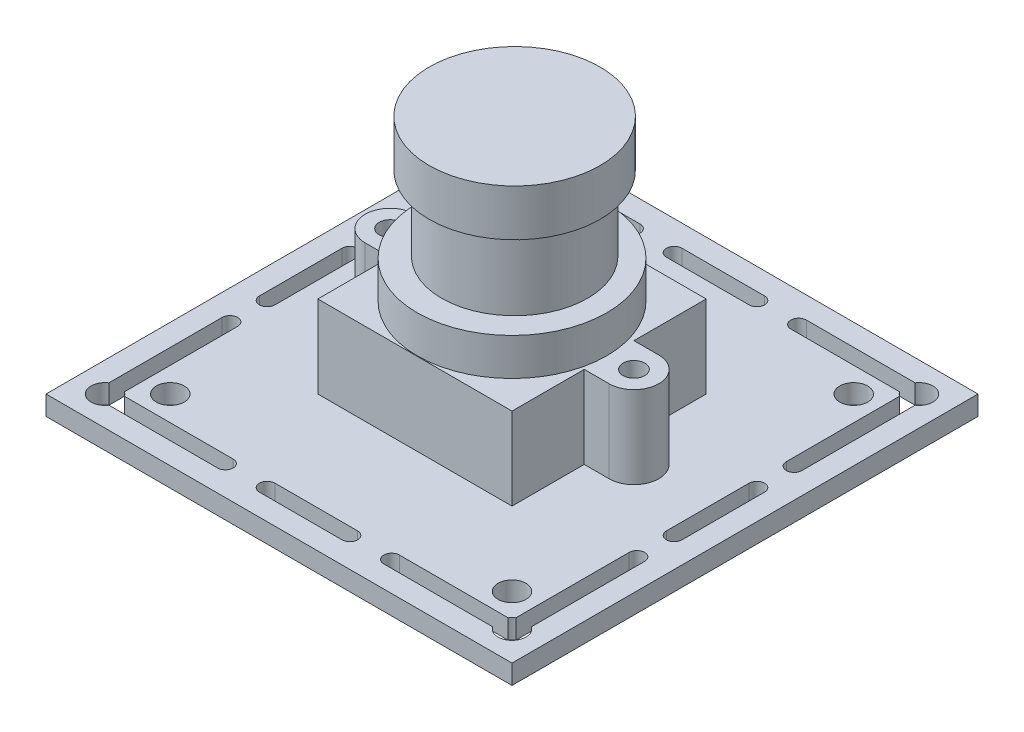
from build123d import *

# Parameters (mm, degrees)
SKETCH1_W           = 38.1
SKETCH1_H           = 38.1
BOSS_EXTRUDE1_DEPTH = 1.5875
SKETCH4_R           = 1.143
CUT_EXTRUDE2_DEPTH  = 7.874
SKETCH6_W           = 15.875
SKETCH6_H           = 15.875
BOSS_EXTRUDE2_DEPTH = 6.731
SKETCH7_R           = 0.889
BOSS_EXTRUDE3_DEPTH = 6.731
SKETCH8_R           = 7.747
BOSS_EXTRUDE4_DEPTH = 3.048
SKETCH9_R           = 5.969
BOSS_EXTRUDE5_DEPTH = 6.096
SKETCH10_R          = 6.985
BOSS_EXTRUDE6_DEPTH = 3.81
SKETCH11_W          = 9.906
SKETCH11_H          = 4.572
BOSS_EXTRUDE7_DEPTH = 8.255


with BuildPart() as part:
    # Sketch1 → Boss-Extrude1 (new body)
    with BuildSketch(Plane(origin=(0, 0, 0), x_dir=(1, 0, 0), z_dir=(0, 1, 0))):
        with Locations((-252.591789549, -315.673153846)):
            Rectangle(SKETCH1_W, SKETCH1_H)
    extrude(amount=BOSS_EXTRUDE1_DEPTH)

    # Sketch4 → Cut-Extrude2 (cut)
    with BuildSketch(Plane(origin=(0, 1.5875, 0), x_dir=(1, 0, 0), z_dir=(0, 1, 0))):
        with Locations((-266.561789549, -301.703153846)):
            Circle(SKETCH4_R)
        with Locations((-238.621789549, -301.703153846)):
            Circle(SKETCH4_R)
        with Locations((-266.561789549, -329.643153846)):
            Circle(SKETCH4_R)
        with Locations((-238.621789549, -329.643153846)):
            Circle(SKETCH4_R)
        with BuildLine():
            Line((-269.863789549, -312.294953846), (-269.863789549, -319.051353846))
            ThreePointArc((-269.863789549, -319.051353846), (-269.228789549, -319.686353846), (-268.593789549, -319.051353846))
            Line((-268.593789549, -319.051353846), (-268.593789549, -312.294953846))
            ThreePointArc((-268.593789549, -312.294953846), (-269.228789549, -311.659953846), (-269.863789549, -312.294953846))
        make_face()
        with BuildLine():
            Line((-259.385291519, -298.401153846), (-268.278408573, -298.401153846))
            ThreePointArc((-268.278408573, -298.401153846), (-270.0370126, -298.227930795), (-269.863789549, -299.986534822))
            Line((-269.863789549, -299.986534822), (-269.863789549, -309.246953846))
            ThreePointArc((-269.863789549, -309.246953846), (-269.228789549, -309.881953846), (-268.593789549, -309.246953846))
            Line((-268.593789549, -309.246953846), (-268.593789549, -299.986534822))
            ThreePointArc((-268.593789549, -299.986534822), (-268.420566498, -299.844376897), (-268.278408573, -299.671153846))
            Line((-268.278408573, -299.671153846), (-259.385291519, -299.671153846))
            ThreePointArc((-259.385291519, -299.671153846), (-258.750291519, -299.036153846), (-259.385291519, -298.401153846))
        make_face()
        with BuildLine():
            Line((-255.969989549, -298.401153846), (-249.213589549, -298.401153846))
            ThreePointArc((-249.213589549, -298.401153846), (-248.578589549, -299.036153846), (-249.213589549, -299.671153846))
            Line((-249.213589549, -299.671153846), (-255.969989549, -299.671153846))
            ThreePointArc((-255.969989549, -299.671153846), (-256.604989549, -299.036153846), (-255.969989549, -298.401153846))
        make_face()
        with BuildLine():
            Line((-236.589789549, -309.246953846), (-236.589789549, -299.986534822))
            ThreePointArc((-236.589789549, -299.986534822), (-236.7630126, -299.844376897), (-236.905170525, -299.671153846))
            Line((-236.905170525, -299.671153846), (-245.798287579, -299.671153846))
            ThreePointArc((-245.798287579, -299.671153846), (-246.433287579, -299.036153846), (-245.798287579, -298.401153846))
            Line((-245.798287579, -298.401153846), (-236.905170525, -298.401153846))
            ThreePointArc((-236.905170525, -298.401153846), (-235.146566498, -298.227930795), (-235.319789549, -299.986534822))
            Line((-235.319789549, -299.986534822), (-235.319789549, -309.246953846))
            ThreePointArc((-235.319789549, -309.246953846), (-235.954789549, -309.881953846), (-236.589789549, -309.246953846))
        make_face()
        with BuildLine():
            Line((-236.589789549, -312.294953846), (-236.589789549, -319.051353846))
            ThreePointArc((-236.589789549, -319.051353846), (-235.954789549, -319.686353846), (-235.319789549, -319.051353846))
            Line((-235.319789549, -319.051353846), (-235.319789549, -312.294953846))
            ThreePointArc((-235.319789549, -312.294953846), (-235.954789549, -311.659953846), (-236.589789549, -312.294953846))
        make_face()
        with BuildLine():
            Line((-245.798287579, -332.945153846), (-236.905170525, -332.945153846))
            ThreePointArc((-236.905170525, -332.945153846), (-235.146566498, -333.118376897), (-235.319789549, -331.35977287))
            Line((-235.319789549, -331.35977287), (-235.319789549, -322.099353846))
            ThreePointArc((-235.319789549, -322.099353846), (-235.954789549, -321.464353846), (-236.589789549, -322.099353846))
            Line((-236.589789549, -322.099353846), (-236.589789549, -331.35977287))
            ThreePointArc((-236.589789549, -331.35977287), (-236.7630126, -331.501930795), (-236.905170525, -331.675153846))
            Line((-236.905170525, -331.675153846), (-245.798287579, -331.675153846))
            ThreePointArc((-245.798287579, -331.675153846), (-246.433287579, -332.310153846), (-245.798287579, -332.945153846))
        make_face()
        with BuildLine():
            Line((-268.593789549, -322.099353846), (-268.593789549, -331.35977287))
            ThreePointArc((-268.593789549, -331.35977287), (-268.420566498, -331.501930795), (-268.278408573, -331.675153846))
            Line((-268.278408573, -331.675153846), (-259.385291519, -331.675153846))
            ThreePointArc((-259.385291519, -331.675153846), (-258.750291519, -332.310153846), (-259.385291519, -332.945153846))
            Line((-259.385291519, -332.945153846), (-268.278408573, -332.945153846))
            ThreePointArc((-268.278408573, -332.945153846), (-270.0370126, -333.118376897), (-269.863789549, -331.35977287))
            Line((-269.863789549, -331.35977287), (-269.863789549, -322.099353846))
            ThreePointArc((-269.863789549, -322.099353846), (-269.228789549, -321.464353846), (-268.593789549, -322.099353846))
        make_face()
        with BuildLine():
            Line((-255.969989549, -331.675153846), (-249.213589549, -331.675153846))
            ThreePointArc((-249.213589549, -331.675153846), (-248.578589549, -332.310153846), (-249.213589549, -332.945153846))
            Line((-249.213589549, -332.945153846), (-255.969989549, -332.945153846))
            ThreePointArc((-255.969989549, -332.945153846), (-256.604989549, -332.310153846), (-255.969989549, -331.675153846))
        make_face()
    extrude(amount=-CUT_EXTRUDE2_DEPTH, mode=Mode.SUBTRACT)

    # Sketch6 → Boss-Extrude2 (add)
    with BuildSketch(Plane(origin=(0, 1.5875, 0), x_dir=(1, 0, 0), z_dir=(0, 1, 0))):
        with Locations((-252.591789549, -315.673153846)):
            Rectangle(SKETCH6_W, SKETCH6_H)
    extrude(amount=BOSS_EXTRUDE2_DEPTH)

    # Sketch7 → Boss-Extrude3 (add)
    with BuildSketch(Plane(origin=(0, 1.5875, 0), x_dir=(1, 0, 0), z_dir=(0, 1, 0))):
        with BuildLine():
            Line((-242.622289549, -313.641153846), (-244.654289549, -313.641153846))
            Line((-244.654289549, -313.641153846), (-244.654289549, -317.705153846))
            Line((-244.654289549, -317.705153846), (-242.622289549, -317.705153846))
            ThreePointArc((-242.622289549, -317.705153846), (-240.590289549, -315.673153846), (-242.622289549, -313.641153846))
        make_face()
        with Locations((-242.622289549, -315.673153846)):
            Circle(SKETCH7_R, mode=Mode.SUBTRACT)
        with BuildLine():
            Line((-262.561289549, -317.705153846), (-260.529289549, -317.705153846))
            Line((-260.529289549, -317.705153846), (-260.529289549, -313.641153846))
            Line((-260.529289549, -313.641153846), (-262.561289549, -313.641153846))
            ThreePointArc((-262.561289549, -313.641153846), (-264.593289549, -315.673153846), (-262.561289549, -317.705153846))
        make_face()
        with Locations((-262.561289549, -315.673153846)):
            Circle(SKETCH7_R, mode=Mode.SUBTRACT)
    extrude(amount=BOSS_EXTRUDE3_DEPTH)

    # Sketch8 → Boss-Extrude4 (add)
    with BuildSketch(Plane(origin=(0, 8.3185, 0), x_dir=(1, 0, 0), z_dir=(0, 1, 0))):
        with Locations((-252.436354268, -315.828589127)):
            Circle(SKETCH8_R)
    extrude(amount=BOSS_EXTRUDE4_DEPTH)

    # Sketch9 → Boss-Extrude5 (add)
    with BuildSketch(Plane(origin=(0, 11.3665, 0), x_dir=(1, 0, 0), z_dir=(0, 1, 0))):
        with Locations((-252.465375739, -315.583143422)):
            Circle(SKETCH9_R)
    extrude(amount=BOSS_EXTRUDE5_DEPTH)

    # Sketch10 → Boss-Extrude6 (add)
    with BuildSketch(Plane(origin=(0, 17.4625, 0), x_dir=(1, 0, 0), z_dir=(0, 1, 0))):
        with Locations((-252.465375739, -315.583143422)):
            Circle(SKETCH10_R)
    extrude(amount=BOSS_EXTRUDE6_DEPTH)

    # Sketch11 → Boss-Extrude7 (add)
    with BuildSketch(Plane.XZ):
        with Locations((-256.737392156, 301.957153846)):
            Rectangle(SKETCH11_W, SKETCH11_H)
    extrude(amount=BOSS_EXTRUDE7_DEPTH)


solid = part.part
